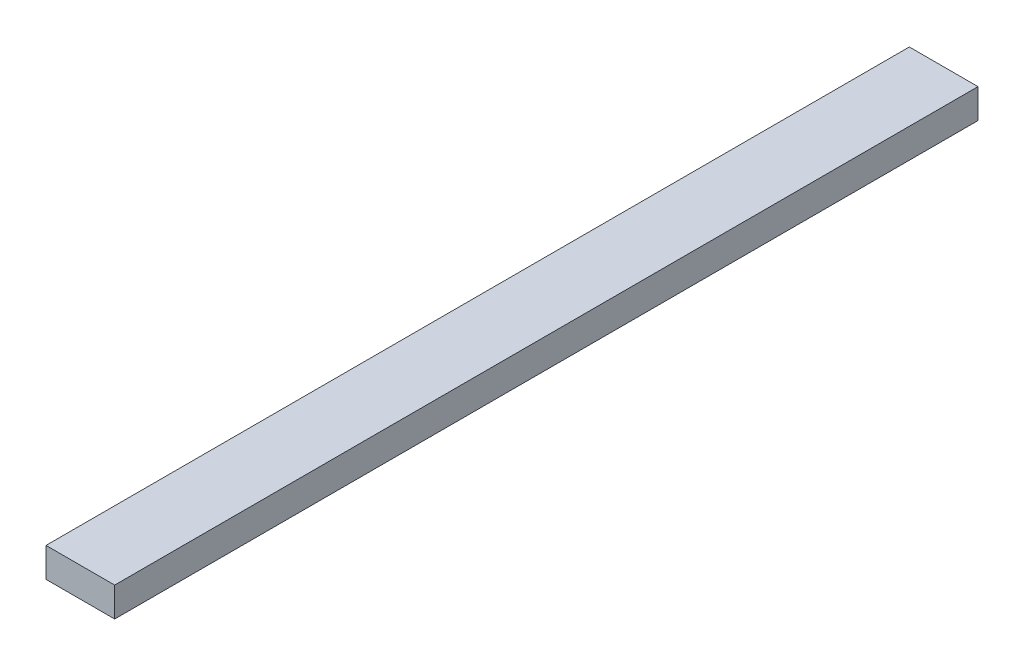
from build123d import *

# Parameters (mm, degrees)
SKETCH1_W           = 88.9
SKETCH1_H           = 38.1
BOSS_EXTRUDE1_DEPTH = 1117.6


with BuildPart() as part:
    # Sketch1 → Boss-Extrude1 (new body)
    with BuildSketch(Plane.XY):
        with Locations((44.45, 19.05)):
            Rectangle(SKETCH1_W, SKETCH1_H)
    extrude(amount=BOSS_EXTRUDE1_DEPTH)


solid = part.part
